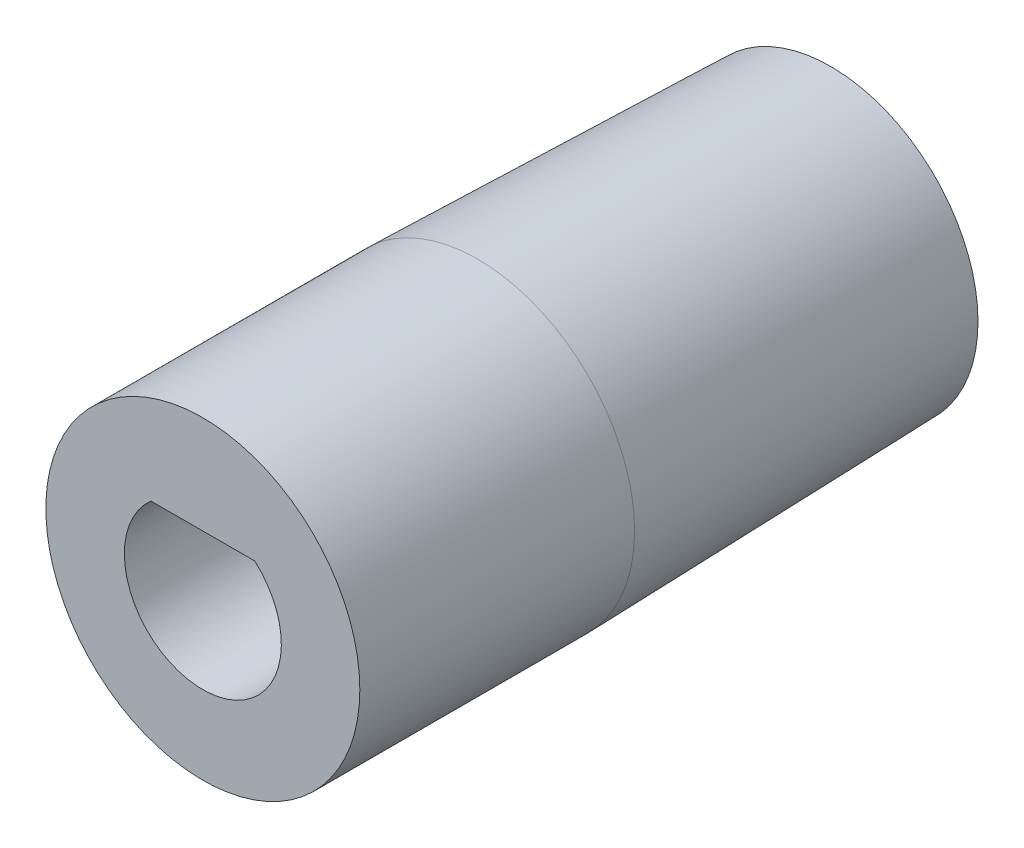
from build123d import *

# Parameters (mm, degrees)
SKETCH_6_R          = 4
EXTRUDE_2_DEPTH     = 7
M4X0_72_D           = 3.3
M4X0_72_DEPTH       = 9
M4X0_72_TIP         = 0.991420021
CUT_EXTRUDE_1_DEPTH = 7


with BuildPart() as part:
    # Эскиз1 → Повернуть1 (revolve)
    with BuildSketch(Plane(origin=(0, 0, 0), x_dir=(1, 0, 0), z_dir=(0, 1, 0))):
        Polygon((0, 9), (3.75, 9), (4, 0), (0, 0), align=None)
    revolve(axis=Axis((0, 0, 0), (0, 0, -1)))

    # Эскиз6 → Бобышка-Вытянуть2 (add)
    with BuildSketch(Plane.XY):
        Circle(SKETCH_6_R)
    extrude(amount=EXTRUDE_2_DEPTH)

    # Отверстие обработанное метчиком M4x0.72
    with Locations(Plane(origin=(0, 0, -9), x_dir=(-1, 0, 0), z_dir=(0, 0, -1))):
        with Locations((0, 0)):
            Hole(M4X0_72_D / 2, depth=M4X0_72_DEPTH)
            with Locations((0, 0, -(M4X0_72_DEPTH + M4X0_72_TIP / 2))):  # 118° drill point
                Cone(0, M4X0_72_D / 2, M4X0_72_TIP, mode=Mode.SUBTRACT)

    # Эскиз9 → Вырез-Вытянуть1 (cut)
    with BuildSketch(Plane.XY.offset(7)):
        with BuildLine():
            Line((-1.322875656, 1.5), (1.322875656, 1.5))
            ThreePointArc((1.322875656, 1.5), (0, -2), (-1.322875656, 1.5))
        make_face()
    extrude(amount=-CUT_EXTRUDE_1_DEPTH, mode=Mode.SUBTRACT)


solid = part.part
